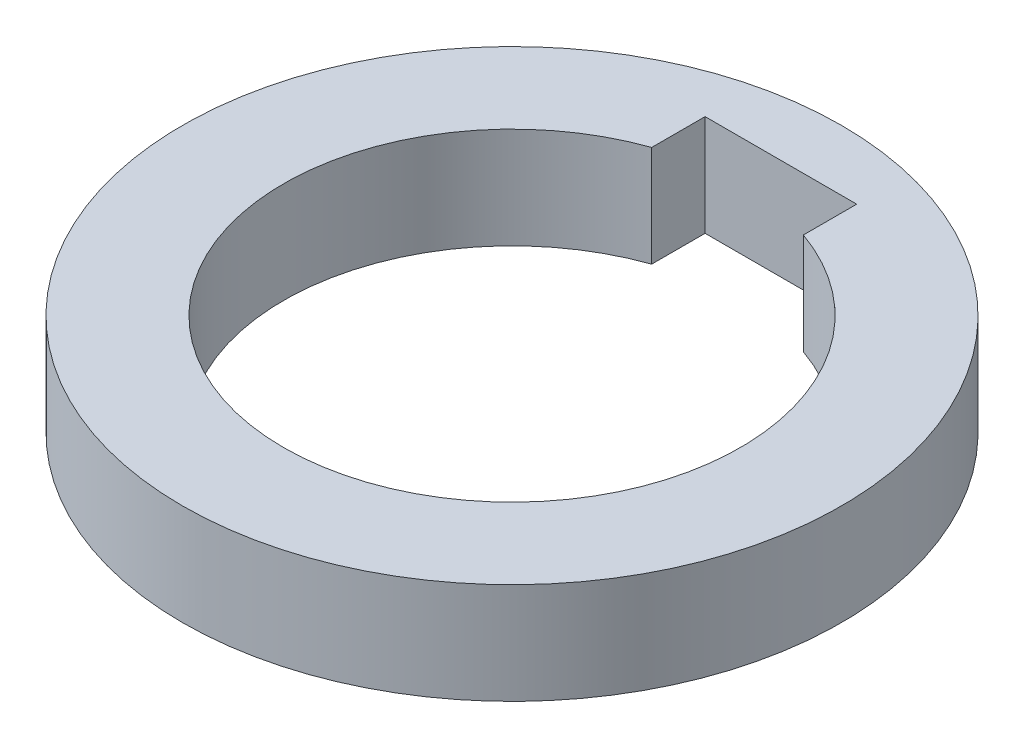
from build123d import *

# Parameters (mm, degrees)
SKETCH1_R      = 32.6
EXTRUDE1_DEPTH = 10


with BuildPart() as part:
    # Sketch1 → Extrude1 (new body)
    with BuildSketch(Plane(origin=(0, 0, 0), x_dir=(1, 0, 0), z_dir=(0, 1, 0))):
        Circle(SKETCH1_R)
        with BuildLine():
            Line((-7.5, 26.6), (-7.5, 21.319240137))
            ThreePointArc((-7.5, 21.319240137), (0, -22.6), (7.5, 21.319240137))
            Line((7.5, 21.319240137), (7.5, 26.6))
            Line((7.5, 26.6), (-7.5, 26.6))
        make_face(mode=Mode.SUBTRACT)
    extrude(amount=EXTRUDE1_DEPTH)


solid = part.part
